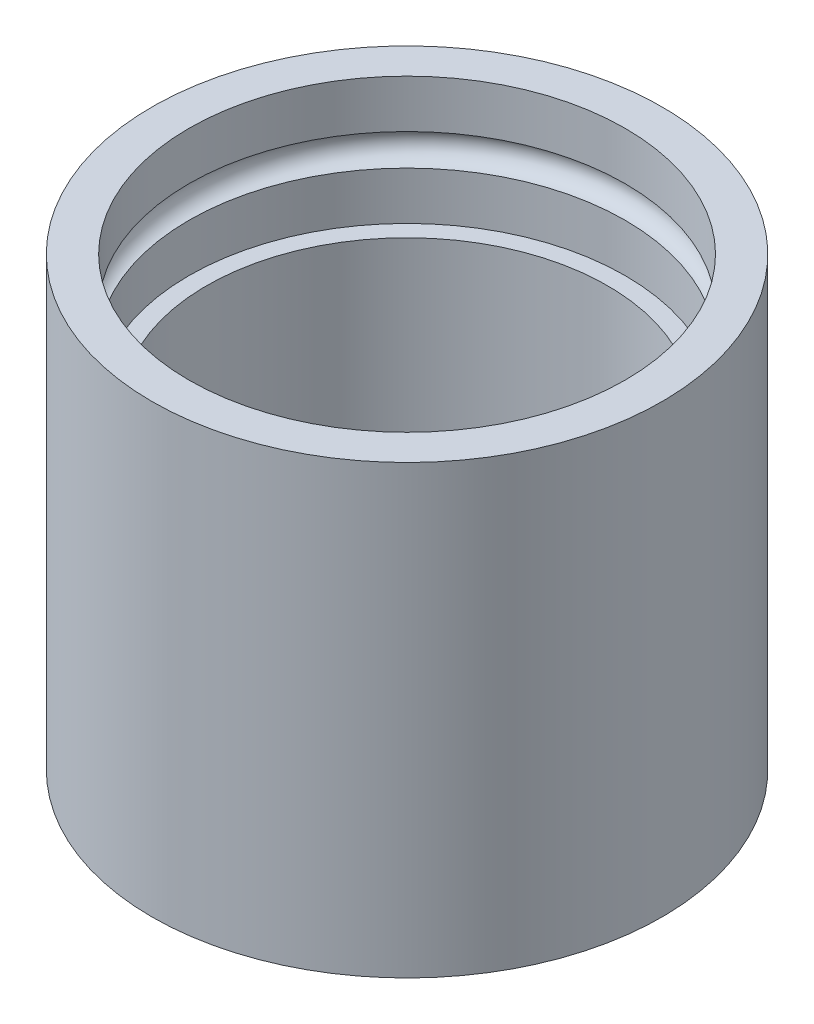
from build123d import *


with BuildPart() as part:
    # Sketch1 → Revolve1 (revolve)
    with BuildSketch(Plane(origin=(0, 0, 0), x_dir=(0, 0, -1), z_dir=(1, 0, 0))):
        with BuildLine():
            Line((0, 0), (0, -88.9))
            Line((0, -88.9), (10.16, -88.9))
            Line((10.16, -88.9), (18.4785, -88.9))
            Line((18.4785, -88.9), (18.4785, -76.2))
            Line((18.4785, -76.2), (10.8585, -76.2))
            Line((10.8585, -76.2), (10.8585, -25.403841866))
            Line((10.8585, -25.403841866), (7.366, -25.403841866))
            Line((7.366, -25.403841866), (7.366, -15.857408119))
            ThreePointArc((7.366, -15.857408119), (4.5593, -12.703841866), (7.366, -9.550275614))
            Line((7.366, -9.550275614), (7.366, 0))
            Line((7.366, 0), (0, 0))
        make_face()
    revolve(axis=Axis((0, -28.313229254, -50.8), (0, -1, 0)))


solid = part.part
